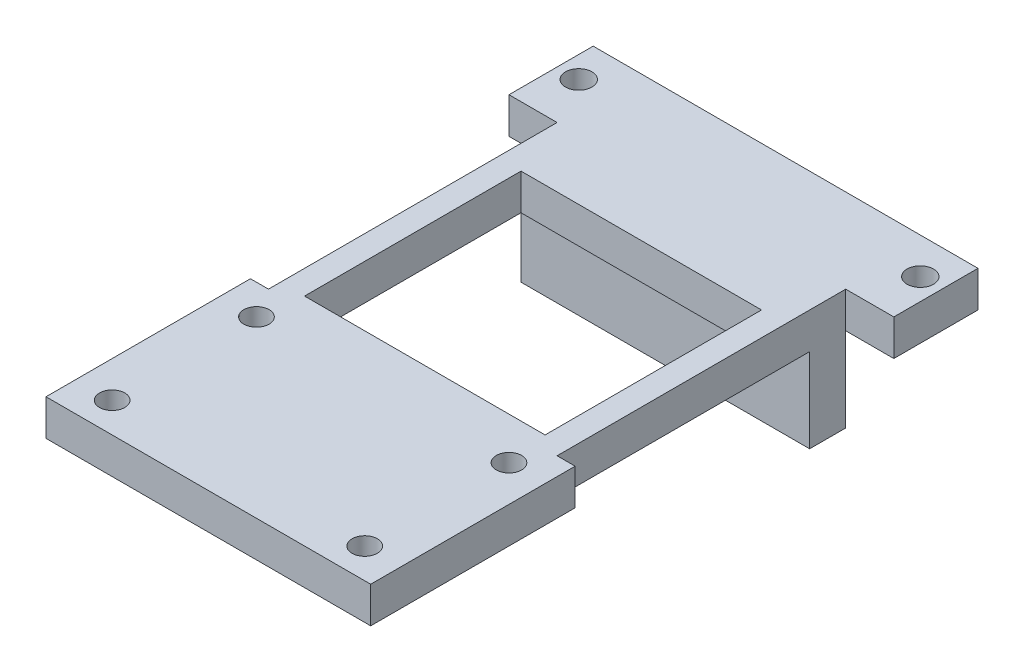
from build123d import *

# Parameters (mm, degrees)
SKETCH_1_W          = 20
SKETCH_1_H          = 10
EXTRUDE_1_DEPTH     = 3
SKETCH_2_W          = 20
SKETCH_2_H          = 3
EXTRUDE_2_DEPTH     = 18
SKETCH_3_W          = 16
SKETCH_3_H          = 12
CUT_EXTRUDE_1_DEPTH = 8
EXTRUDE_3_DEPTH     = 3
SKETCH_5_R          = 1.05
CUT_EXTRUDE_2_DEPTH = 10
FILLET_2_R          = 1
FILLET_3_R          = 1
FILLET_4_R          = 1
SKETCH_6_W          = 20
SKETCH_6_H          = 21
CUT_EXTRUDE_3_DEPTH = 10
SKETCH_7_W          = 24
SKETCH_7_H          = 24
EXTRUDE_4_DEPTH     = 3
SKETCH_8_W          = 24
SKETCH_8_H          = 3
EXTRUDE_5_DEPTH     = 7
SKETCH_9_W          = 20
SKETCH_9_H          = 18
CUT_EXTRUDE_4_DEPTH = 7
SKETCH_10_W         = 32
SKETCH_10_H         = 7
EXTRUDE_6_DEPTH     = 3
SKETCH_11_R         = 1.1
CUT_EXTRUDE_5_DEPTH = 4


with BuildPart() as part:
    # 草图1 → 凸台-拉伸1 (new body)
    with BuildSketch(Plane.XY):
        with Locations((10, 5)):
            Rectangle(SKETCH_1_W, SKETCH_1_H)
    extrude(amount=EXTRUDE_1_DEPTH)

    # 草图2 → 凸台-拉伸2 (add)
    with BuildSketch(Plane.XY.offset(3)):
        with Locations((10, 8.5)):
            Rectangle(SKETCH_2_W, SKETCH_2_H)
    extrude(amount=EXTRUDE_2_DEPTH)

    # 草图3 → 切除-拉伸1 (cut)
    with BuildSketch(Plane.XZ.offset(-7)):
        with Locations((10, 12)):
            Rectangle(SKETCH_3_W, SKETCH_3_H)
    extrude(amount=-CUT_EXTRUDE_1_DEPTH, mode=Mode.SUBTRACT)

    # 草图4 → 凸台-拉伸3 (add)
    with BuildSketch(Plane.XZ.offset(-7)):
        Polygon((0, 21), (-3.5, 21), (-3.5, 38), (23.5, 38), (23.5, 21), align=None)
    extrude(amount=-EXTRUDE_3_DEPTH)

    # 草图5 → 切除-拉伸2 (cut)
    with BuildSketch(Plane.XZ.offset(-7)):
        with Locations((-0.5, 23.5)):
            Circle(SKETCH_5_R)
        with Locations((20.5, 23.5)):
            Circle(SKETCH_5_R)
        with Locations((20.5, 35.5)):
            Circle(SKETCH_5_R)
        with Locations((-0.5, 35.5)):
            Circle(SKETCH_5_R)
    extrude(amount=-CUT_EXTRUDE_2_DEPTH, mode=Mode.SUBTRACT)

    # 圆角2
    fillet_2_edges = [part.edges().sort_by_distance(p)[0] for p in [
        (10, 0, 3),
    ]]
    fillet(fillet_2_edges, radius=FILLET_2_R)

    # 圆角3
    fillet_3_edges = [part.edges().sort_by_distance(p)[0] for p in [
        (0, 4, 3),
        (20, 4, 3),
        (20, 0, 1),
        (20, 0.292893219, 2.707106781),
        (0, 0, 1),
        (0, 0.292893219, 2.707106781),
    ]]
    fillet(fillet_3_edges, radius=FILLET_3_R)

    # 圆角4
    fillet_4_edges = [part.edges().sort_by_distance(p)[0] for p in [
        (2, 7, 12),
        (10, 7, 6),
        (18, 7, 12),
        (10, 7, 18),
    ]]
    fillet(fillet_4_edges, radius=FILLET_4_R)

    # 草图6 → 切除-拉伸3 (cut)
    with BuildSketch(Plane(origin=(0, 10, 0), x_dir=(1, 0, 0), z_dir=(0, 1, 0))):
        with Locations((10, -10.5)):
            Rectangle(SKETCH_6_W, SKETCH_6_H)
    extrude(amount=-CUT_EXTRUDE_3_DEPTH, mode=Mode.SUBTRACT)

    # 草图7 → 凸台-拉伸4 (add)
    with BuildSketch(Plane(origin=(0, 10, 0), x_dir=(1, 0, 0), z_dir=(0, 1, 0))):
        with Locations((10, -9)):
            Rectangle(SKETCH_7_W, SKETCH_7_H)
    extrude(amount=-EXTRUDE_4_DEPTH)

    # 草图8 → 凸台-拉伸5 (add)
    with BuildSketch(Plane.XZ.offset(-7)):
        with Locations((10, -1.5)):
            Rectangle(SKETCH_8_W, SKETCH_8_H)
    extrude(amount=EXTRUDE_5_DEPTH)

    # 草图9 → 切除-拉伸4 (cut)
    with BuildSketch(Plane(origin=(0, 10, 0), x_dir=(1, 0, 0), z_dir=(0, 1, 0))):
        with Locations((10, -11)):
            Rectangle(SKETCH_9_W, SKETCH_9_H)
    extrude(amount=-CUT_EXTRUDE_4_DEPTH, mode=Mode.SUBTRACT)

    # 草图10 → 凸台-拉伸6 (add)
    with BuildSketch(Plane(origin=(0, 10, 0), x_dir=(1, 0, 0), z_dir=(0, 1, 0))):
        with Locations((10, 6.5)):
            Rectangle(SKETCH_10_W, SKETCH_10_H)
    extrude(amount=-EXTRUDE_6_DEPTH)

    # 草图11 → 切除-拉伸5 (cut)
    with BuildSketch(Plane(origin=(0, 10, 0), x_dir=(1, 0, 0), z_dir=(0, 1, 0))):
        with Locations((-4.2, 7)):
            Circle(SKETCH_11_R)
        with Locations((24.2, 7)):
            Circle(SKETCH_11_R)
    extrude(amount=-CUT_EXTRUDE_5_DEPTH, mode=Mode.SUBTRACT)


solid = part.part
